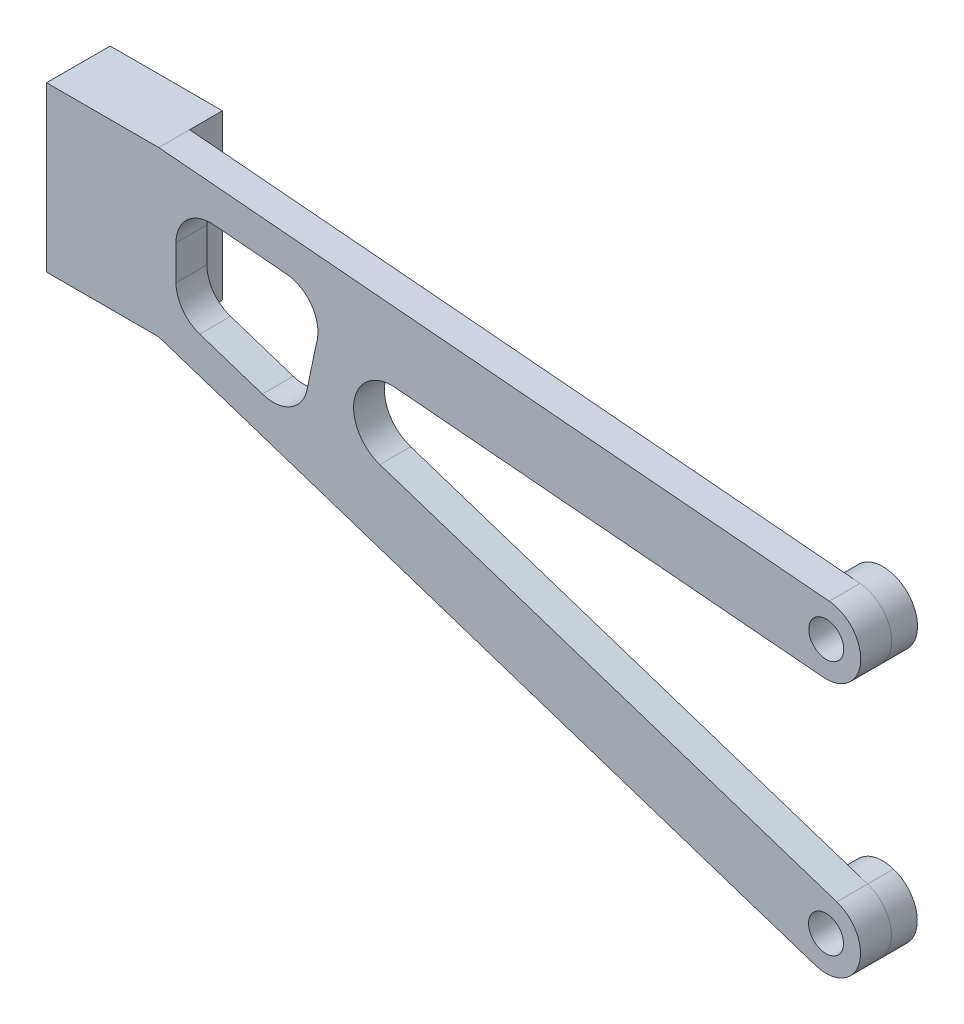
from build123d import *

# Parameters (mm, degrees)
SKETCH2_R           = 2.025
BOSS_EXTRUDE1_DEPTH = 6.575
SKETCH3_W           = 85
SKETCH3_H           = 45
SKETCH3_R           = 4
CUT_EXTRUDE1_DEPTH  = 3
BOSS_EXTRUDE2_DEPTH = 0.8


with BuildPart() as part:
    # Sketch2 → Boss-Extrude1 (new body)
    with BuildSketch(Plane.XY):
        with BuildLine():
            Line((0, 19), (0, 0))
            Line((0, 0), (13, 0))
            Line((13, 0), (89.060496565, -25.00806589))
            ThreePointArc((89.060496565, -25.00806589), (94.109744025, -22.45755612), (91.559234256, -17.40830866))
            Line((91.559234256, -17.40830866), (38.617230635, -0.001413167))
            ThreePointArc((38.617230635, -0.001413167), (35.662685114, 5.091263251), (40.379460771, 8.614999867))
            Line((40.379460771, 8.614999867), (89.992289035, 4.346816993))
            ThreePointArc((89.992289035, 4.346816993), (94.32042132, 7.989243509), (90.677994805, 12.317375794))
            Line((90.677994805, 12.317375794), (13, 19))
            Line((13, 19), (0, 19))
        make_face()
        with Locations((90.33514192, 8.332096393)):
            Circle(SKETCH2_R, mode=Mode.SUBTRACT)
        with Locations((90.30986541, -21.208187275)):
            Circle(SKETCH2_R, mode=Mode.SUBTRACT)
        with BuildLine():
            Line((15, 10.45427111), (15, 6.44857097))
            ThreePointArc((15, 6.44857097), (15.759824435, 4.103093981), (17.750631155, 2.648692356))
            Line((17.750631155, 2.648692356), (24.997412202, 0.266010331))
            ThreePointArc((24.997412202, 0.266010331), (28.242503446, 0.599321176), (30.16022559, 3.238270793))
            Line((30.16022559, 3.238270793), (31.357615095, 8.900202452))
            ThreePointArc((31.357615095, 8.900202452), (30.656648203, 12.111093006), (27.787023436, 13.713100006))
            Line((27.787023436, 13.713100006), (19.342852885, 14.43955051))
            ThreePointArc((19.342852885, 14.43955051), (16.29550481, 13.401423255), (15, 10.45427111))
        make_face(mode=Mode.SUBTRACT)
    extrude(amount=BOSS_EXTRUDE1_DEPTH)

    # Sketch3 → Cut-Extrude1 (cut)
    with BuildSketch(Plane(origin=(0, 0, 0), x_dir=(-1, 0, 0), z_dir=(0, 0, -1))):
        with Locations((-55.5, -3.5)):
            Rectangle(SKETCH3_W, SKETCH3_H)
        with Locations((-90.3351, 8.3321)):
            Circle(SKETCH3_R, mode=Mode.SUBTRACT)
        with Locations((-90.3096, -21.2081)):
            Circle(SKETCH3_R, mode=Mode.SUBTRACT)
    extrude(amount=-CUT_EXTRUDE1_DEPTH, mode=Mode.SUBTRACT)

    # Sketch4 → Boss-Extrude2 (add)
    with BuildSketch(Plane(origin=(0, 0, 0), x_dir=(-1, 0, 0), z_dir=(0, 0, -1))):
        Polygon((0, 19), (-13, 19), (-13, 0), (-10.5, 0), (-10.5, 16.5), (0, 16.5), align=None)
    extrude(amount=BOSS_EXTRUDE2_DEPTH)


solid = part.part
